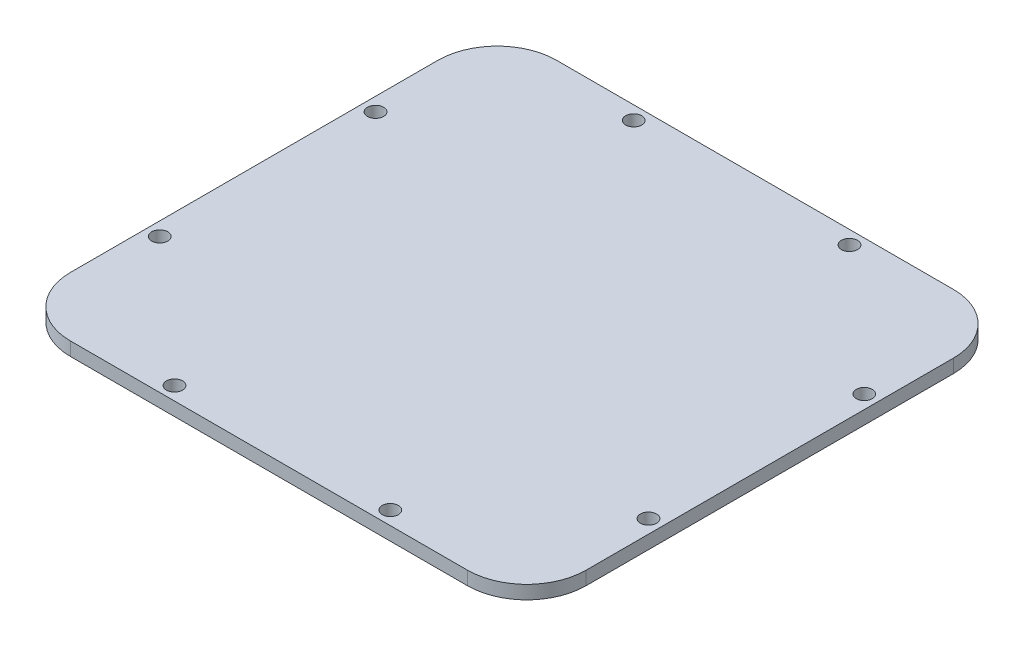
from build123d import *

# Parameters (mm, degrees)
SKETCH1_W             = 121.412
SKETCH1_H             = 114.4524
BOSS_EXTRUDE1_DEPTH   = 3.175
FILLET2_R             = 13.97
F_6_CLEARANCE_HOLE1_D = 3.7973


with BuildPart() as part:
    # Sketch1 → Boss-Extrude1 (new body)
    with BuildSketch(Plane(origin=(0, 0, 0), x_dir=(1, 0, 0), z_dir=(0, 1, 0))):
        Rectangle(SKETCH1_W, SKETCH1_H)
    extrude(amount=BOSS_EXTRUDE1_DEPTH)

    # Fillet2
    fillet2_edges = [part.edges().sort_by_distance(p)[0] for p in [
        (-60.706, 1.5875, -57.2262),
        (60.706, 1.5875, -57.2262),
        (60.706, 1.5875, 57.2262),
        (-60.706, 1.5875, 57.2262),
    ]]
    fillet(fillet2_edges, radius=FILLET2_R)

    # #6 Clearance Hole1 (through all)
    with Locations(Plane.XZ):
        with Locations((-25.4, 54.0512), (-25.4, -54.0512), (-57.531, -25.4), (-57.531, 25.4)):
            f_6_clearance_hole1 = Hole(F_6_CLEARANCE_HOLE1_D / 2)

    # Mirror1: #6 Clearance Hole1 across plane
    add(f_6_clearance_hole1.mirror(Plane(origin=(0, 0, 0), x_dir=(0, 0, 1), z_dir=(1, 0, 0))), mode=Mode.SUBTRACT)


solid = part.part
